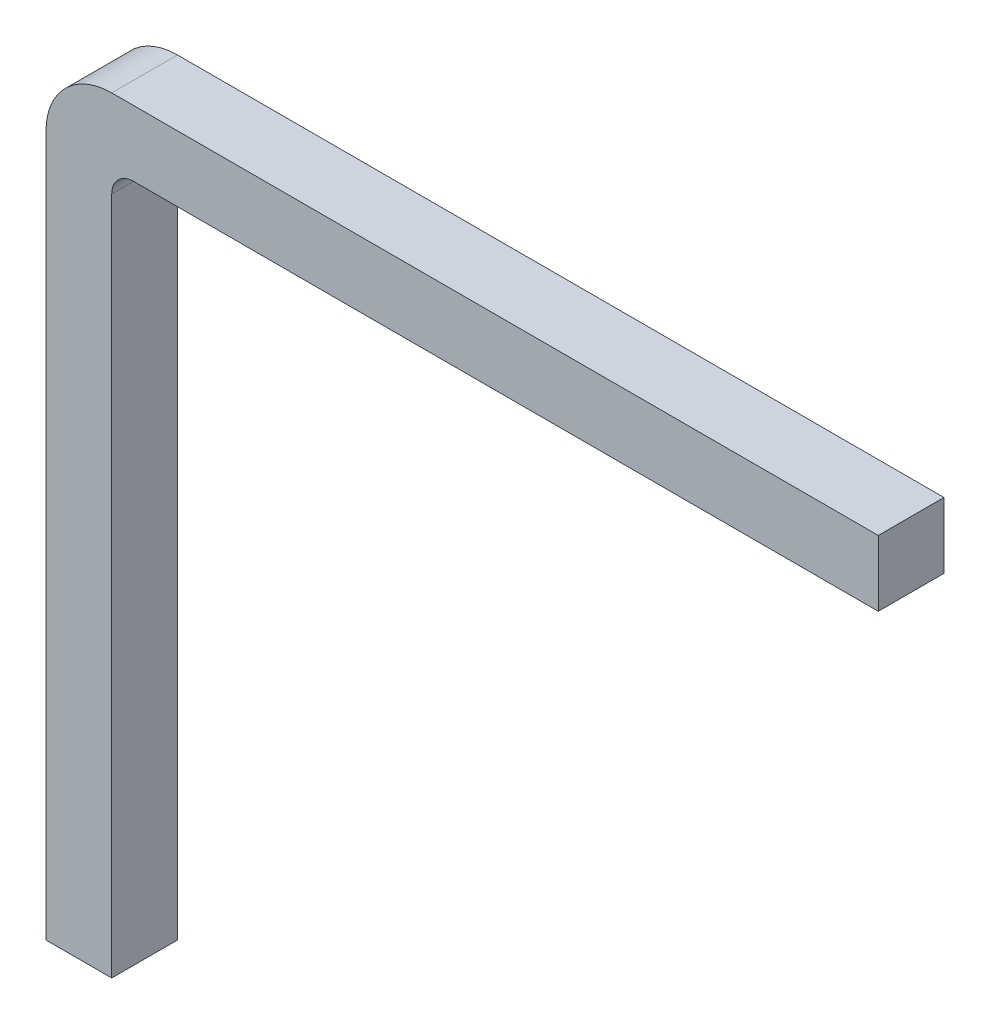
from build123d import *

# Parameters (mm, degrees)
BOSS_EXTRUDE1_DEPTH = 0.3


with BuildPart() as part:
    # Sketch3 → Boss-Extrude1 (new body, symmetric)
    with BuildSketch(Plane.XY):
        with BuildLine():
            Line((0, 0), (-0.3, 0))
            Line((-0.3, 0), (-0.3, 6.4))
            ThreePointArc((-0.3, 6.4), (-0.124264069, 6.824264069), (0.3, 7))
            Line((0.3, 7), (7.3, 7))
            Line((7.3, 7), (7.3, 6.4))
            Line((7.3, 6.4), (0.5, 6.4))
            ThreePointArc((0.5, 6.4), (0.358578644, 6.341421356), (0.3, 6.2))
            Line((0.3, 6.2), (0.3, 0))
            Line((0.3, 0), (0, 0))
        make_face()
    extrude(amount=BOSS_EXTRUDE1_DEPTH, both=True)


solid = part.part
